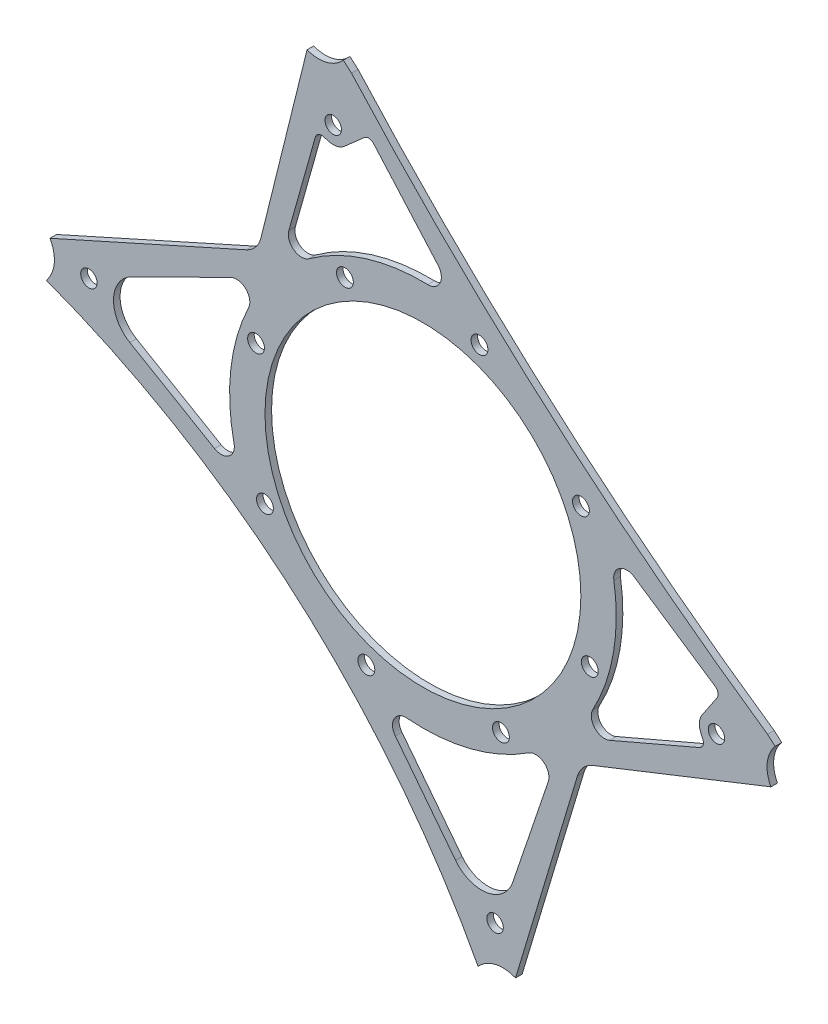
from build123d import *

# Parameters (mm, degrees)
SKETCH4_R           = 3.175
SKETCH4_R_2         = 3.25
BOSS_EXTRUDE1_DEPTH = 2.54
SKETCH5_R           = 12.7
CUT_EXTRUDE1_DEPTH  = 5.08
BOSS_EXTRUDE2_DEPTH = 2.54


with BuildPart() as part:
    # Sketch4 → Boss-Extrude1 (new body)
    with BuildSketch(Plane.XY):
        with BuildLine():
            Line((-176.74227619, 45.132498501), (-186.294911373, 53.501319271))
            Line((-186.294911373, 53.501319271), (-184.20270618, 55.889478066))
            Line((-184.20270618, 55.889478066), (-99.572707218, 93.889403295))
            ThreePointArc((-99.572707218, 93.889403295), (-95.936400091, 96.645129164), (-93.872658654, 100.714247725))
            Line((-93.872658654, 100.714247725), (-73.734272023, 181.984262474))
            Line((-73.734272023, 181.984262474), (-71.64206683, 184.372421269))
            Line((-71.64206683, 184.372421269), (-58.940232346, 173.244667072))
            ThreePointArc((-58.940232346, 173.244667072), (17.165554399, 98.128149473), (101.640161914, 32.564267056))
            Line((101.640161914, 32.564267056), (114.125157675, 21.626479751))
            Line((114.125157675, 21.626479751), (112.032952483, 19.238320955))
            Line((112.032952483, 19.238320955), (34.250907029, -11.547413739))
            ThreePointArc((34.250907029, -11.547413739), (30.507681387, -14.12116226), (28.260245615, -18.068940382))
            Line((28.260245615, -18.068940382), (1.564518325, -106.856463453))
            Line((1.564518325, -106.856463453), (-0.527686867, -109.244622248))
            Line((-0.527686867, -109.244622248), (-10.080322049, -100.875801479))
            ThreePointArc((-10.080322049, -100.875801479), (-80.021168146, -12.587414945), (-176.74227619, 45.132498501))
        make_face()
        with Locations((-160.278926398, 53.978352412)):
            Circle(SKETCH4_R, mode=Mode.SUBTRACT)
        with Locations((-3.529256732, -83.108546775)):
            Circle(SKETCH4_R, mode=Mode.SUBTRACT)
        with Locations((81.919540542, 22.826625413)):
            Circle(SKETCH4_R, mode=Mode.SUBTRACT)
        with Locations((-65.999265009, 152.414529532)):
            Circle(SKETCH4_R, mode=Mode.SUBTRACT)
        with Locations((-95.775994763, 64.547904473)):
            Circle(SKETCH4_R_2, mode=Mode.SUBTRACT)
        with Locations((-92.345604955, 12.616132759)):
            Circle(SKETCH4_R_2, mode=Mode.SUBTRACT)
        with Locations((-53.198645122, -21.679523284)):
            Circle(SKETCH4_R_2, mode=Mode.SUBTRACT)
        with Locations((-1.266873408, -18.249133476)):
            Circle(SKETCH4_R_2, mode=Mode.SUBTRACT)
        with Locations((33.028782635, 20.897826357)):
            Circle(SKETCH4_R_2, mode=Mode.SUBTRACT)
        with Locations((29.598392827, 72.829598071)):
            Circle(SKETCH4_R_2, mode=Mode.SUBTRACT)
        with Locations((-9.548567006, 107.125254114)):
            Circle(SKETCH4_R_2, mode=Mode.SUBTRACT)
        with Locations((-61.48033872, 103.694864306)):
            Circle(SKETCH4_R_2, mode=Mode.SUBTRACT)
        with BuildLine():
            Line((-83.124086465, 108.558482428), (-72.906170409, 144.859339501))
            ThreePointArc((-72.906170409, 144.859339501), (-71.703410878, 146.386634264), (-69.772970974, 146.616115326))
            Line((-69.772970974, 146.616115326), (-67.788615701, 146.057561693))
            ThreePointArc((-67.788615701, 146.057561693), (-64.531511448, 145.975700797), (-61.631660764, 147.461061135))
            Line((-61.631660764, 147.461061135), (-53.995233146, 154.194301567))
            ThreePointArc((-53.995233146, 154.194301567), (-52.156051315, 154.824118981), (-50.410205207, 153.968969201))
            Line((-50.410205207, 153.968969201), (-25.527970385, 125.74906719))
            ThreePointArc((-25.527970385, 125.74906719), (-24.735411209, 120.240061903), (-29.468069359, 117.311028592))
            ThreePointArc((-29.468069359, 117.311028592), (-53.532229742, 113.969062176), (-75.246987371, 103.073106251))
            ThreePointArc((-75.246987371, 103.073106251), (-81.13713529, 103.013263889), (-83.124086465, 108.558482428))
        make_face(mode=Mode.SUBTRACT)
        with BuildLine():
            Line((16.986640929, -25.648722449), (3.285829101, -66.077745579))
            ThreePointArc((3.285829101, -66.077745579), (-6.63716699, -74.525917572), (-18.776818461, -69.786052217))
            Line((-18.776818461, -69.786052217), (-42.034504369, -39.805719002))
            ThreePointArc((-42.034504369, -39.805719002), (-42.485464898, -34.268691956), (-37.596964591, -31.62963935))
            ThreePointArc((-37.596964591, -31.62963935), (-13.10838548, -29.619424245), (9.399371164, -19.763849047))
            ThreePointArc((9.399371164, -19.763849047), (15.288833977, -20.004169525), (16.986640929, -25.648722449))
        make_face(mode=Mode.SUBTRACT)
        with BuildLine():
            Line((40.69710548, 0.081884812), (75.33851288, 14.985942183))
            ThreePointArc((75.33851288, 14.985942183), (76.694329343, 16.379147659), (76.667891318, 18.322999714))
            Line((76.667891318, 18.322999714), (75.853173782, 20.216642591))
            ThreePointArc((75.853173782, 20.216642591), (75.343592919, 23.434678742), (76.434608248, 26.504713738))
            Line((76.434608248, 26.504713738), (82.104868563, 34.960463346))
            ThreePointArc((82.104868563, 34.960463346), (82.487292302, 36.86650948), (81.409928575, 38.484702046))
            Line((81.409928575, 38.484702046), (50.16227754, 59.438765709))
            ThreePointArc((50.16227754, 59.438765709), (44.596887673, 59.499797903), (42.315826006, 54.422983254))
            ThreePointArc((42.315826006, 54.422983254), (42.168235941, 30.128317757), (34.223256987, 7.169008885))
            ThreePointArc((34.223256987, 7.169008885), (34.938709714, 1.322167772), (40.69710548, 0.081884812))
        make_face(mode=Mode.SUBTRACT)
        with BuildLine():
            Line((-105.512311204, 81.669494492), (-143.713248966, 62.806648573))
            ThreePointArc((-143.713248966, 62.806648573), (-150.782631627, 51.862619993), (-144.494183598, 40.451951557))
            Line((-144.494183598, 40.451951557), (-111.798776698, 21.36105828))
            ThreePointArc((-111.798776698, 21.36105828), (-106.250665651, 21.63862745), (-104.273833103, 26.83003515))
            ThreePointArc((-104.273833103, 26.83003515), (-105.486548337, 51.342432917), (-98.680560053, 74.92223033))
            ThreePointArc((-98.680560053, 74.92223033), (-99.693477447, 80.728909632), (-105.512311204, 81.669494492))
        make_face(mode=Mode.SUBTRACT)
        with BuildLine():
            Line((93.329108368, 30.491933184), (94.570600217, 29.65941303))
            ThreePointArc((94.570600217, 29.65941303), (96.24244212, 26.144229017), (93.954385503, 22.995202038))
            Line((93.954385503, 22.995202038), (91.863858259, 22.095777322))
            ThreePointArc((91.863858259, 22.095777322), (90.11439141, 22.0719831), (88.860506481, 23.292217917))
            Line((88.860506481, 23.292217917), (88.136116535, 24.97591294))
            ThreePointArc((88.136116535, 24.97591294), (87.959723159, 26.089848531), (88.337382312, 27.152552952))
            Line((88.337382312, 27.152552952), (90.157293538, 29.866487195))
            ThreePointArc((90.157293538, 29.866487195), (91.613666847, 30.83611455), (93.329108368, 30.491933184))
        make_face(mode=Mode.SUBTRACT)
        with BuildLine():
            Line((-60.104144331, 161.506711917), (-62.555111231, 159.345629503))
            ThreePointArc((-62.555111231, 159.345629503), (-63.558905699, 158.831466309), (-64.686364863, 158.859802773))
            Line((-64.686364863, 158.859802773), (-66.450715015, 159.356429663))
            ThreePointArc((-66.450715015, 159.356429663), (-67.825280301, 160.438913241), (-68.031813258, 162.176309155))
            Line((-68.031813258, 162.176309155), (-67.41518612, 164.366980273))
            ThreePointArc((-67.41518612, 164.366980273), (-64.594485575, 167.049371452), (-60.889934446, 165.854434246))
            Line((-60.889934446, 165.854434246), (-59.901345202, 164.733237062))
            ThreePointArc((-59.901345202, 164.733237062), (-59.334509529, 163.077973415), (-60.104144331, 161.506711917))
        make_face(mode=Mode.SUBTRACT)
        with BuildLine():
            ThreePointArc((-58.363398568, 97.382472993), (-71.543951219, -3.129778676), (26.361239359, 23.157354329))
            ThreePointArc((26.361239359, 23.157354329), (8.796739091, 88.575509506), (-58.363398568, 97.382472993))
        make_face(mode=Mode.SUBTRACT)
    extrude(amount=BOSS_EXTRUDE1_DEPTH)

    # Sketch5 → Cut-Extrude1 (cut)
    with BuildSketch(Plane.XY):
        with Locations((-71.64206683, 184.372421269)):
            Circle(SKETCH5_R)
        with Locations((-186.294911373, 53.501319271)):
            Circle(SKETCH5_R)
        with Locations((-0.527686867, -109.244622248)):
            Circle(SKETCH5_R)
        with Locations((114.125157675, 21.626479751)):
            Circle(SKETCH5_R)
    extrude(amount=CUT_EXTRUDE1_DEPTH, mode=Mode.SUBTRACT)

    # Sketch4_4 → Boss-Extrude2 (add)
    with BuildSketch(Plane.XY):
        with BuildLine():
            Line((94.570600217, 29.65941303), (93.329108368, 30.491933184))
            ThreePointArc((93.329108368, 30.491933184), (91.613666847, 30.83611455), (90.157293538, 29.866487195))
            Line((90.157293538, 29.866487195), (88.337382312, 27.152552952))
            ThreePointArc((88.337382312, 27.152552952), (87.959723159, 26.089848531), (88.136116535, 24.97591294))
            Line((88.136116535, 24.97591294), (88.860506481, 23.292217917))
            ThreePointArc((88.860506481, 23.292217917), (90.11439141, 22.0719831), (91.863858259, 22.095777322))
            Line((91.863858259, 22.095777322), (93.954385503, 22.995202038))
            ThreePointArc((93.954385503, 22.995202038), (96.24244212, 26.144229017), (94.570600217, 29.65941303))
        make_face()
        with BuildLine():
            Line((-62.555111231, 159.345629503), (-60.104144331, 161.506711917))
            ThreePointArc((-60.104144331, 161.506711917), (-59.334509529, 163.077973415), (-59.901345202, 164.733237062))
            Line((-59.901345202, 164.733237062), (-60.889934446, 165.854434246))
            ThreePointArc((-60.889934446, 165.854434246), (-64.594485575, 167.049371452), (-67.41518612, 164.366980273))
            Line((-67.41518612, 164.366980273), (-68.031813258, 162.176309155))
            ThreePointArc((-68.031813258, 162.176309155), (-67.825280301, 160.438913241), (-66.450715015, 159.356429663))
            Line((-66.450715015, 159.356429663), (-64.686364863, 158.859802773))
            ThreePointArc((-64.686364863, 158.859802773), (-63.558905699, 158.831466309), (-62.555111231, 159.345629503))
        make_face()
    extrude(amount=BOSS_EXTRUDE2_DEPTH)


solid = part.part
